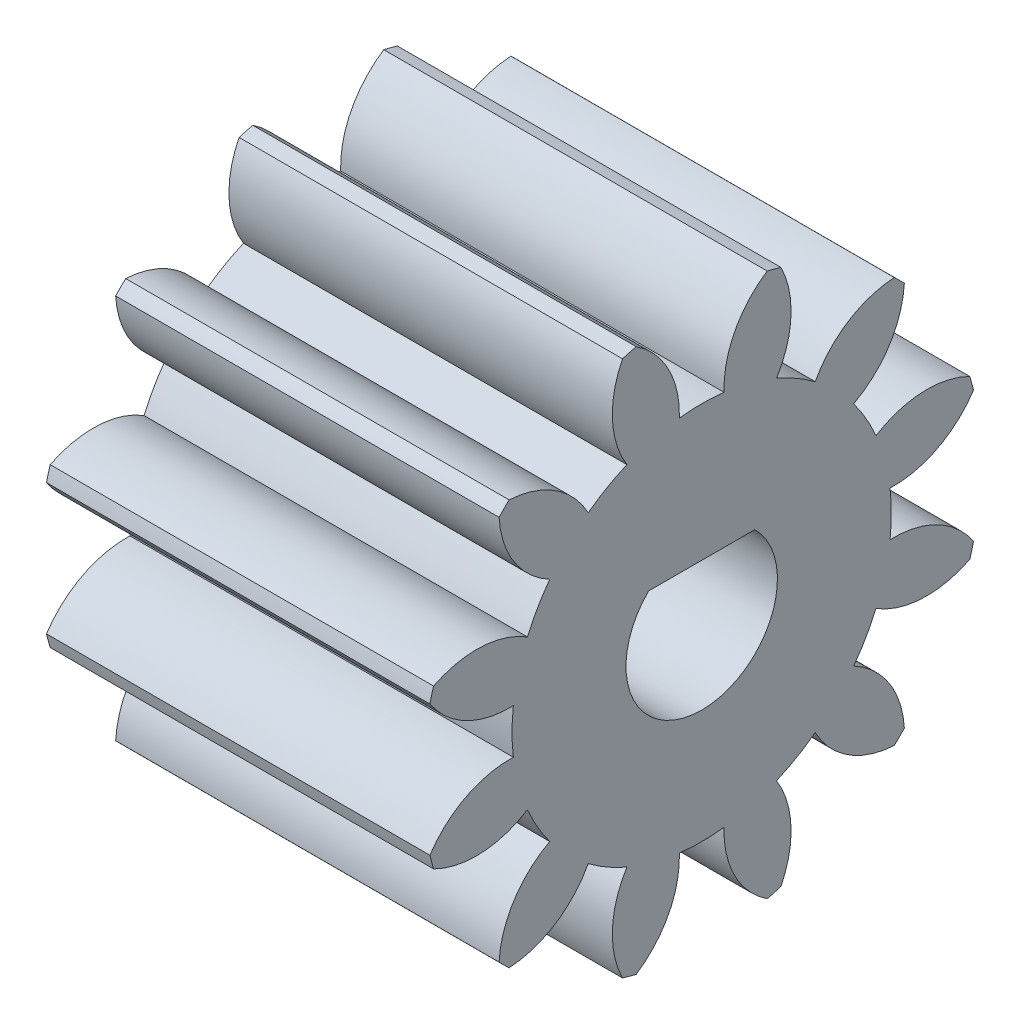
from build123d import *

# Parameters (mm, degrees)
BASPROSKE_W        = 12
BASPROSKE_H        = 8.75
TOOTHCUT_DEPTH     = 18.237314176
TEETHCUTS_COUNT    = 12
TEETHCUTS_ANGLE    = 330
BORSKE_R           = 0.4
BORE_DEPTH         = 50.0000508
CUT_EXTRUDE1_DEPTH = 17.991923373


with BuildPart() as part:
    # BasProSke → Base-Revolve (revolve)
    with BuildSketch(Plane(origin=(0, 0, 0), x_dir=(1, 0, 0), z_dir=(0, 1, 0)), mode=Mode.PRIVATE) as base_revolve_sk:
        with Locations((6, 4.375)):
            Rectangle(BASPROSKE_W, BASPROSKE_H)
    revolve(base_revolve_sk.sketch.rotate(Axis((-10, 0, 0), (1, 0, 0)), 180), axis=Axis((-10, 0, 0), (1, 0, 0)))

    # TooCutSke → ToothCut (cut, through all)
    with BuildSketch(Plane(origin=(0, 0, 0), x_dir=(0, 0, -1), z_dir=(1, 0, 0))):
        with BuildLine():
            ThreePointArc((0.699286786, 5.895170077), (0, 5.9365), (-0.699286786, 5.895170077))
            ThreePointArc((-0.699286786, 5.895170077), (-1.040581249, 7.393099844), (-2.078649209, 8.525659073))
            ThreePointArc((-2.078649209, 8.525659073), (0, 8.7754), (2.078649209, 8.525659073))
            ThreePointArc((2.078649209, 8.525659073), (1.040581249, 7.393099844), (0.699286786, 5.895170077))
        make_face()
    toothcut = extrude(amount=TOOTHCUT_DEPTH, mode=Mode.SUBTRACT)

    # TeethCuts: ToothCut ×12 about axis
    teethcuts_axis = Axis((-10, 0, 0), (1, 0, 0))
    for i in range(1, TEETHCUTS_COUNT):
        add(toothcut.rotate(teethcuts_axis, i * TEETHCUTS_ANGLE / (TEETHCUTS_COUNT - 1)), mode=Mode.SUBTRACT)

    # BorSke → Bore (cut, symmetric)
    with BuildSketch(Plane(origin=(0, 0, 0), x_dir=(0, 0, -1), z_dir=(1, 0, 0))):
        with Locations(Location((0, 0, 0), (0, 0, 180))):
            Circle(BORSKE_R)
    extrude(amount=BORE_DEPTH, both=True, mode=Mode.SUBTRACT)

    # Sketch1 → Cut-Extrude1 (cut, through all)
    with BuildSketch(Plane(origin=(12, 0, 0), x_dir=(0, 0, -1), z_dir=(1, 0, 0))):
        with BuildLine():
            Line((-1.661565527, 1.69), (1.661565527, 1.69))
            ThreePointArc((1.661565527, 1.69), (0, -2.37), (-1.661565527, 1.69))
        make_face()
    extrude(amount=-CUT_EXTRUDE1_DEPTH, mode=Mode.SUBTRACT)


solid = part.part
